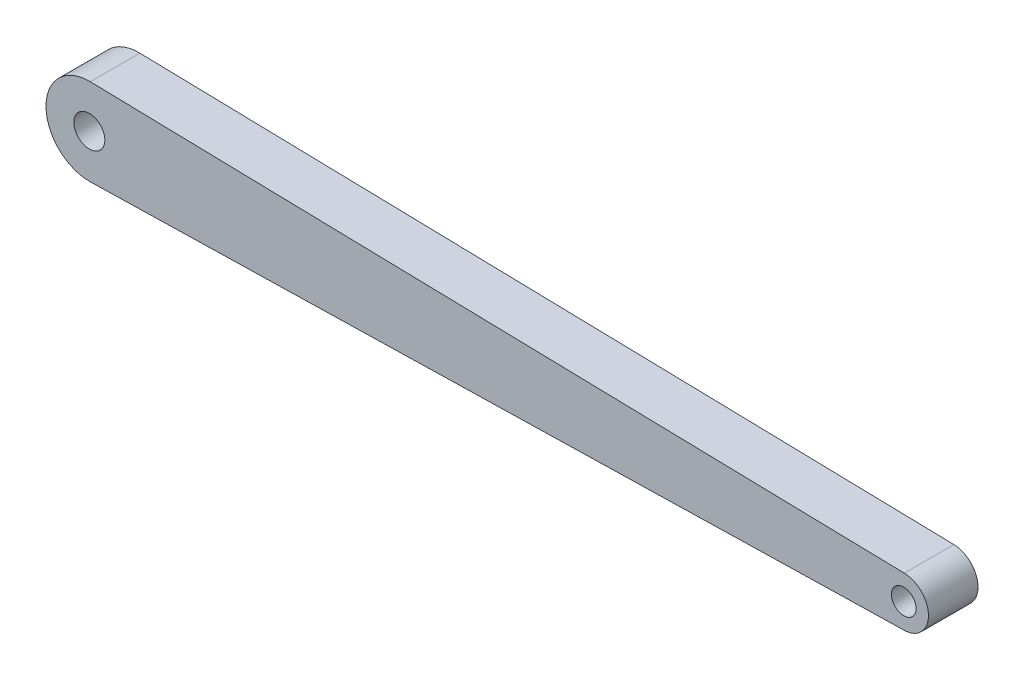
from build123d import *

# Parameters (mm, degrees)
SKETCH1_R           = 20
SKETCH1_R_2         = 25
BOSS_EXTRUDE1_DEPTH = 40


with BuildPart() as part:
    # Sketch1 → Boss-Extrude1 (new body, symmetric)
    with BuildSketch(Plane.XY):
        with BuildLine():
            Line((-1313.403041825, 69.981781376), (0.912547529, 39.989589358))
            ThreePointArc((0.912547529, 39.989589358), (40, 0), (0.912547529, -39.989589358))
            Line((0.912547529, -39.989589358), (-1313.403041825, -69.981781376))
            ThreePointArc((-1313.403041825, -69.981781376), (-1385, 0), (-1313.403041825, 69.981781376))
        make_face()
        Circle(SKETCH1_R, mode=Mode.SUBTRACT)
        with Locations((-1315, 0)):
            Circle(SKETCH1_R_2, mode=Mode.SUBTRACT)
    extrude(amount=BOSS_EXTRUDE1_DEPTH, both=True)


solid = part.part
